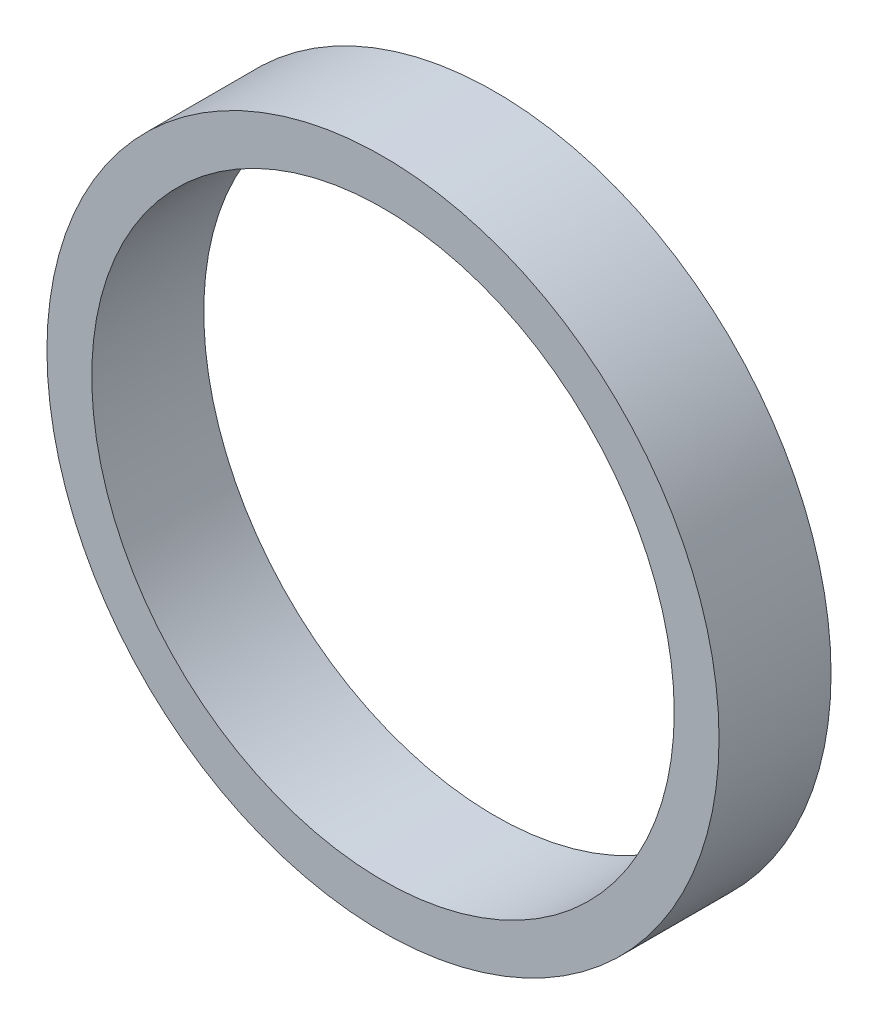
from build123d import *

# Parameters (mm, degrees)
CROQUIS1_R              = 1.5
CROQUIS1_R_2            = 1.3
SALIENTE_EXTRUIR1_DEPTH = 0.5


with BuildPart() as part:
    # Croquis1 → Saliente-Extruir1 (new body)
    with BuildSketch(Plane.XY):
        Circle(CROQUIS1_R)
        Circle(CROQUIS1_R_2, mode=Mode.SUBTRACT)
    extrude(amount=SALIENTE_EXTRUIR1_DEPTH)


solid = part.part
